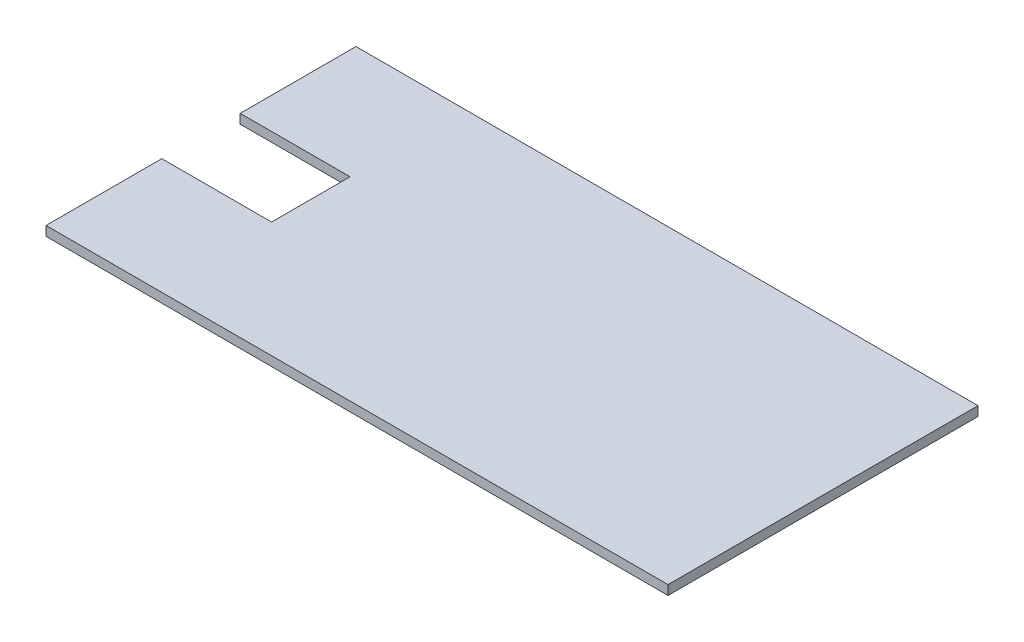
from build123d import *

# Parameters (mm, degrees)
BOSS_EXTRUDE1_DEPTH = 3


with BuildPart() as part:
    # Sketch1 → Boss-Extrude1 (new body)
    with BuildSketch(Plane(origin=(0, 0, 0), x_dir=(1, 0, 0), z_dir=(0, 1, 0))):
        Polygon((-60.578159562, -33.396078056), (-60.578159562, -70.296078056), (137.681840438, -70.296078056), (137.681840438, 28.503921944), (-60.578159562, 28.503921944), (-60.578159562, -8.396078056), (-25.578159562, -8.396078056), (-25.578159562, -33.396078056), align=None)
    extrude(amount=BOSS_EXTRUDE1_DEPTH)


solid = part.part
